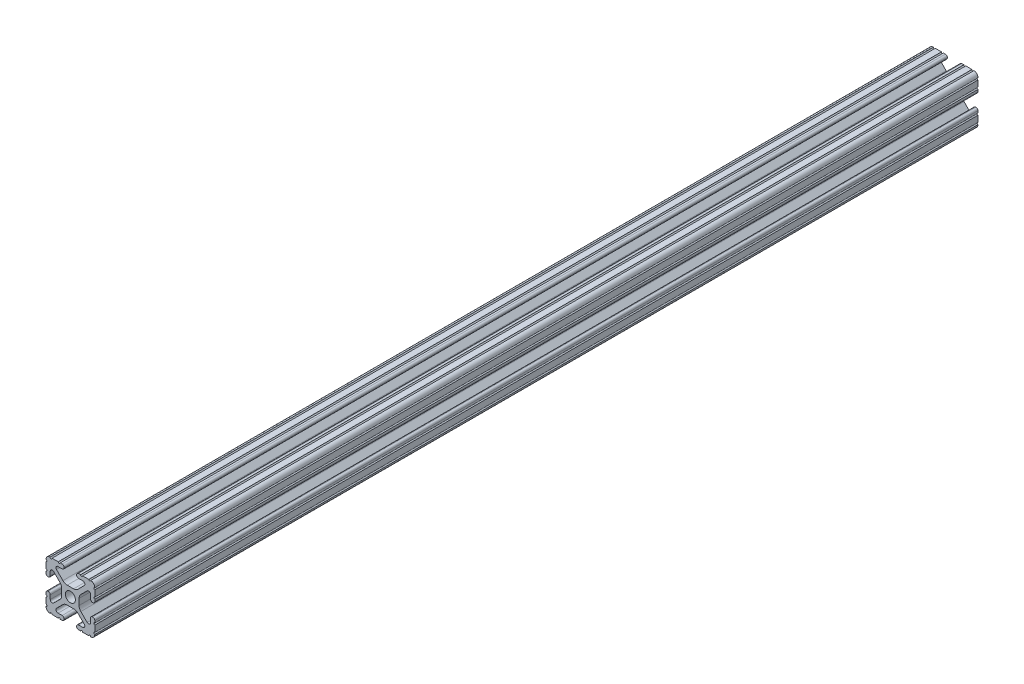
from build123d import *

# Parameters (mm, degrees)
SKETCH1_R           = 2.6035
BOSS_EXTRUDE1_DEPTH = 229.87


with BuildPart() as part:
    # Sketch1 → Boss-Extrude1 (new body, symmetric)
    with BuildSketch(Plane.XY):
        with BuildLine():
            Line((-7.179650497, -8.645192506), (-3.952270251, -5.423690499))
            ThreePointArc((-3.952270251, -5.423690499), (-2.922936451, -4.736929036), (-1.709253557, -4.4958))
            Line((-1.709253557, -4.4958), (1.709253557, -4.4958))
            ThreePointArc((1.709253557, -4.4958), (2.922936451, -4.736929036), (3.952270251, -5.423690499))
            Line((3.952270251, -5.423690499), (7.179650497, -8.645192506))
            ThreePointArc((7.179650497, -8.645192506), (7.41473083, -9.822813117), (6.416408329, -10.4902))
            Line((6.416408329, -10.4902), (4.287512407, -10.4902))
            ThreePointArc((4.287512407, -10.4902), (3.54574862, -10.79744862), (3.2385, -11.539212407))
            Line((3.2385, -11.539212407), (3.2385, -11.650987593))
            ThreePointArc((3.2385, -11.650987593), (3.54574862, -12.39275138), (4.287512407, -12.7))
            Line((4.287512407, -12.7), (5.317126718, -12.7))
            ThreePointArc((5.317126718, -12.7), (5.825126718, -12.192), (6.333126718, -12.7))
            Line((6.333126718, -12.7), (9.550443118, -12.7))
            ThreePointArc((9.550443118, -12.7), (10.058366869, -12.192000006), (10.566443095, -12.699847501))
            ThreePointArc((10.566443095, -12.699847501), (12.082537762, -12.08250727), (12.699846982, -10.566399977))
            ThreePointArc((12.699846982, -10.566399977), (12.192000006, -10.058323491), (12.7, -9.5504))
            Line((12.7, -9.5504), (12.7, -6.3330836))
            ThreePointArc((12.7, -6.3330836), (12.192, -5.8250836), (12.7, -5.3170836))
            Line((12.7, -5.3170836), (12.7, -4.287469289))
            ThreePointArc((12.7, -4.287469289), (12.39275138, -3.545705502), (11.650987593, -3.238456882))
            Line((11.650987593, -3.238456882), (11.539212407, -3.238456882))
            ThreePointArc((11.539212407, -3.238456882), (10.79744862, -3.545705502), (10.4902, -4.287469289))
            Line((10.4902, -4.287469289), (10.4902, -6.402089023))
            ThreePointArc((10.4902, -6.402089023), (9.856505071, -7.351067942), (8.737131347, -7.129408934))
            Line((8.737131347, -7.129408934), (5.441005833, -3.840816462))
            ThreePointArc((5.441005833, -3.840816462), (4.750877967, -2.809883091), (4.5085, -1.593185507))
            Line((4.5085, -1.593185507), (4.5085, 1.593185507))
            ThreePointArc((4.5085, 1.593185507), (4.750877967, 2.809883091), (5.441005833, 3.840816462))
            Line((5.441005833, 3.840816462), (8.737131347, 7.129408934))
            ThreePointArc((8.737131347, 7.129408934), (9.856505071, 7.351067942), (10.4902, 6.402089023))
            Line((10.4902, 6.402089023), (10.4902, 4.287469289))
            ThreePointArc((10.4902, 4.287469289), (10.79744862, 3.545705502), (11.539212407, 3.238456882))
            Line((11.539212407, 3.238456882), (11.650987593, 3.238456882))
            ThreePointArc((11.650987593, 3.238456882), (12.39275138, 3.545705502), (12.7, 4.287469289))
            Line((12.7, 4.287469289), (12.7, 5.3170836))
            ThreePointArc((12.7, 5.3170836), (12.192, 5.8250836), (12.7, 6.3330836))
            Line((12.7, 6.3330836), (12.7, 9.5504))
            ThreePointArc((12.7, 9.5504), (12.192000006, 10.058323491), (12.699846982, 10.566399977))
            ThreePointArc((12.699846982, 10.566399977), (12.082537762, 12.08250727), (10.566443095, 12.699847501))
            ThreePointArc((10.566443095, 12.699847501), (10.058366869, 12.192000006), (9.550443118, 12.7))
            Line((9.550443118, 12.7), (6.333126718, 12.7))
            ThreePointArc((6.333126718, 12.7), (5.825126718, 12.192), (5.317126718, 12.7))
            Line((5.317126718, 12.7), (4.287512407, 12.7))
            ThreePointArc((4.287512407, 12.7), (3.54574862, 12.39275138), (3.2385, 11.650987593))
            Line((3.2385, 11.650987593), (3.2385, 11.539212407))
            ThreePointArc((3.2385, 11.539212407), (3.54574862, 10.79744862), (4.287512407, 10.4902))
            Line((4.287512407, 10.4902), (6.476788598, 10.4902))
            ThreePointArc((6.476788598, 10.4902), (7.432222385, 9.85140422), (7.207036008, 8.724370562))
            Line((7.207036008, 8.724370562), (3.898272566, 5.423169045))
            ThreePointArc((3.898272566, 5.423169045), (2.869120213, 4.736787962), (1.655778399, 4.4958))
            Line((1.655778399, 4.4958), (-1.655778399, 4.4958))
            ThreePointArc((-1.655778399, 4.4958), (-2.869120213, 4.736787962), (-3.898272566, 5.423169045))
            Line((-3.898272566, 5.423169045), (-7.207036008, 8.724370562))
            ThreePointArc((-7.207036008, 8.724370562), (-7.432222385, 9.85140422), (-6.476788598, 10.4902))
            Line((-6.476788598, 10.4902), (-4.287512407, 10.4902))
            ThreePointArc((-4.287512407, 10.4902), (-3.54574862, 10.79744862), (-3.2385, 11.539212407))
            Line((-3.2385, 11.539212407), (-3.2385, 11.650987593))
            ThreePointArc((-3.2385, 11.650987593), (-3.54574862, 12.39275138), (-4.287512407, 12.7))
            Line((-4.287512407, 12.7), (-5.317126718, 12.7))
            ThreePointArc((-5.317126718, 12.7), (-5.825126718, 12.192), (-6.333126718, 12.7))
            Line((-6.333126718, 12.7), (-9.550443118, 12.7))
            ThreePointArc((-9.550443118, 12.7), (-10.058366869, 12.192000006), (-10.566443095, 12.699847501))
            ThreePointArc((-10.566443095, 12.699847501), (-12.082537762, 12.08250727), (-12.699846982, 10.566399977))
            ThreePointArc((-12.699846982, 10.566399977), (-12.192000006, 10.058323491), (-12.7, 9.5504))
            Line((-12.7, 9.5504), (-12.7, 6.3330836))
            ThreePointArc((-12.7, 6.3330836), (-12.192, 5.8250836), (-12.7, 5.3170836))
            Line((-12.7, 5.3170836), (-12.7, 4.287469289))
            ThreePointArc((-12.7, 4.287469289), (-12.39275138, 3.545705502), (-11.650987593, 3.238456882))
            Line((-11.650987593, 3.238456882), (-11.539212407, 3.238456882))
            ThreePointArc((-11.539212407, 3.238456882), (-10.79744862, 3.545705502), (-10.4902, 4.287469289))
            Line((-10.4902, 4.287469289), (-10.4902, 6.402089023))
            ThreePointArc((-10.4902, 6.402089023), (-9.856505071, 7.351067942), (-8.737131347, 7.129408934))
            Line((-8.737131347, 7.129408934), (-5.441005833, 3.840816462))
            ThreePointArc((-5.441005833, 3.840816462), (-4.750877967, 2.809883091), (-4.5085, 1.593185507))
            Line((-4.5085, 1.593185507), (-4.5085, -1.593185507))
            ThreePointArc((-4.5085, -1.593185507), (-4.750877967, -2.809883091), (-5.441005833, -3.840816462))
            Line((-5.441005833, -3.840816462), (-8.737131347, -7.129408934))
            ThreePointArc((-8.737131347, -7.129408934), (-9.856505071, -7.351067942), (-10.4902, -6.402089023))
            Line((-10.4902, -6.402089023), (-10.4902, -4.287469289))
            ThreePointArc((-10.4902, -4.287469289), (-10.79744862, -3.545705502), (-11.539212407, -3.238456882))
            Line((-11.539212407, -3.238456882), (-11.650987593, -3.238456882))
            ThreePointArc((-11.650987593, -3.238456882), (-12.39275138, -3.545705502), (-12.7, -4.287469289))
            Line((-12.7, -4.287469289), (-12.7, -5.3170836))
            ThreePointArc((-12.7, -5.3170836), (-12.192, -5.8250836), (-12.7, -6.3330836))
            Line((-12.7, -6.3330836), (-12.7, -9.5504))
            ThreePointArc((-12.7, -9.5504), (-12.192000006, -10.058323491), (-12.699846982, -10.566399977))
            ThreePointArc((-12.699846982, -10.566399977), (-12.082537762, -12.08250727), (-10.566443095, -12.699847501))
            ThreePointArc((-10.566443095, -12.699847501), (-10.058366869, -12.192000006), (-9.550443118, -12.7))
            Line((-9.550443118, -12.7), (-6.333126718, -12.7))
            ThreePointArc((-6.333126718, -12.7), (-5.825126718, -12.192), (-5.317126718, -12.7))
            Line((-5.317126718, -12.7), (-4.287512407, -12.7))
            ThreePointArc((-4.287512407, -12.7), (-3.54574862, -12.39275138), (-3.2385, -11.650987593))
            Line((-3.2385, -11.650987593), (-3.2385, -11.539212407))
            ThreePointArc((-3.2385, -11.539212407), (-3.54574862, -10.79744862), (-4.287512407, -10.4902))
            Line((-4.287512407, -10.4902), (-6.416408329, -10.4902))
            ThreePointArc((-6.416408329, -10.4902), (-7.41473083, -9.822813117), (-7.179650497, -8.645192506))
        make_face()
        Circle(SKETCH1_R, mode=Mode.SUBTRACT)
    extrude(amount=BOSS_EXTRUDE1_DEPTH, both=True)


solid = part.part
